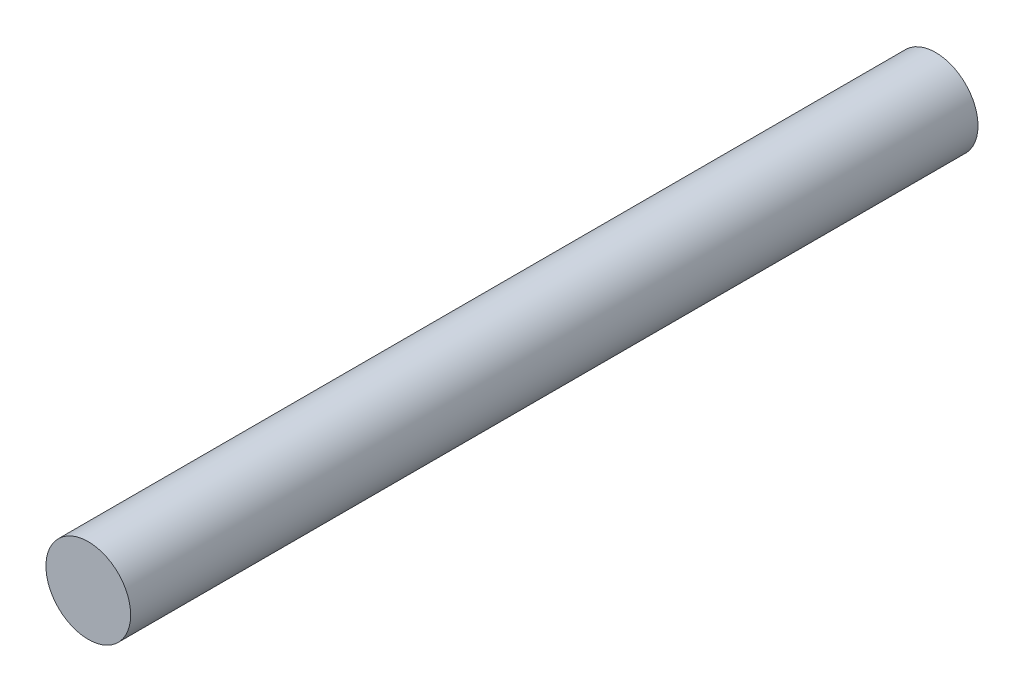
from build123d import *

# Parameters (mm, degrees)
CROQUIS1_R              = 0.1
SALIENTE_EXTRUIR1_DEPTH = 2


with BuildPart() as part:
    # Croquis1 → Saliente-Extruir1 (new body)
    with BuildSketch(Plane.XY):
        Circle(CROQUIS1_R)
    extrude(amount=SALIENTE_EXTRUIR1_DEPTH)


solid = part.part
